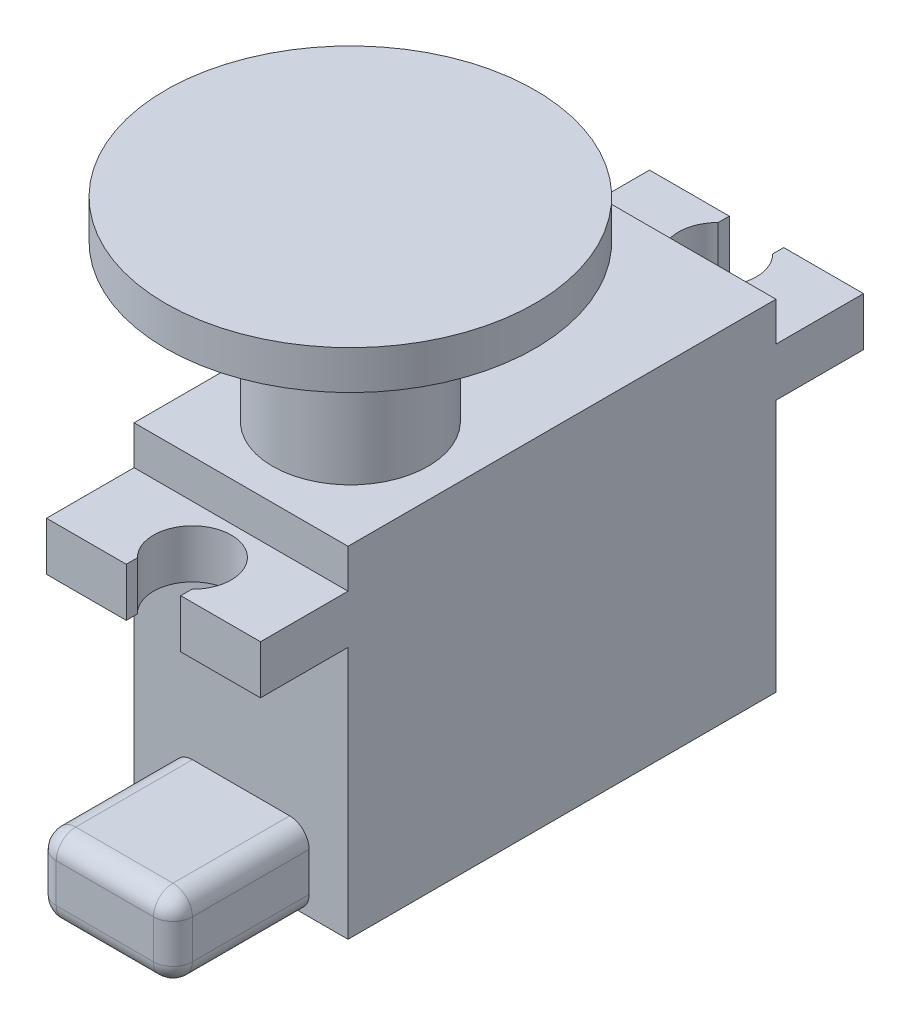
from build123d import *

# Parameters (mm, degrees)
SKETCH1_W            = 11
SKETCH1_H            = 22
BOSS_EXTRUDE1_DEPTH  = 17.5
SKETCH8_W            = 7
SKETCH8_H            = 4
BOSS_EXTRUDE6_DEPTH  = 7
FILLET1_R            = 1
FILLET2_R            = 1
SKETCH9_W            = 11
SKETCH9_H            = 2.5
BOSS_EXTRUDE7_DEPTH  = 4.5
SKETCH10_W           = 11
SKETCH10_H           = 2.5
BOSS_EXTRUDE8_DEPTH  = 4.5
CUT_EXTRUDE1_DEPTH   = 5
SKETCH2_R            = 4
BOSS_EXTRUDE9_DEPTH  = 8
SKETCH13_R           = 9.5
BOSS_EXTRUDE10_DEPTH = 2


with BuildPart() as part:
    # Sketch1 → Boss-Extrude1 (new body)
    with BuildSketch(Plane(origin=(0, 0, 0), x_dir=(1, 0, 0), z_dir=(0, 1, 0))):
        Rectangle(SKETCH1_W, SKETCH1_H)
    extrude(amount=BOSS_EXTRUDE1_DEPTH)

    # Sketch8 → Boss-Extrude6 (add)
    with BuildSketch(Plane.XY.offset(11)):
        with Locations((0, 2)):
            Rectangle(SKETCH8_W, SKETCH8_H)
    extrude(amount=BOSS_EXTRUDE6_DEPTH)

    # Fillet1
    fillet1_edges = [part.edges().sort_by_distance(p)[0] for p in [
        (-3.5, 0, 14.5),
        (-3.5, 4, 14.5),
        (3.5, 4, 14.5),
        (3.5, 0, 14.5),
    ]]
    fillet(fillet1_edges, radius=FILLET1_R)

    # Fillet2
    fillet2_edges = [part.edges().sort_by_distance(p)[0] for p in [
        (0, 0, 18),
        (-3.5, 2, 18),
        (3.5, 2, 18),
        (0, 4, 18),
        (3.207106781, 0.292893219, 18),
        (3.207106781, 3.707106781, 18),
        (-3.207106781, 3.707106781, 18),
        (-3.207106781, 0.292893219, 18),
    ]]
    fillet(fillet2_edges, radius=FILLET2_R)

    # Sketch9 → Boss-Extrude7 (add)
    with BuildSketch(Plane.XY.offset(11)):
        with Locations((0, 14.25)):
            Rectangle(SKETCH9_W, SKETCH9_H)
    extrude(amount=BOSS_EXTRUDE7_DEPTH)

    # Sketch10 → Boss-Extrude8 (add)
    with BuildSketch(Plane(origin=(0, 0, -11), x_dir=(-1, 0, 0), z_dir=(0, 0, -1))):
        with Locations((0, 14.25)):
            Rectangle(SKETCH10_W, SKETCH10_H)
    extrude(amount=BOSS_EXTRUDE8_DEPTH)

    # Sketch11 → Cut-Extrude1 (cut)
    with BuildSketch(Plane(origin=(0, 17.5, 0), x_dir=(1, 0, 0), z_dir=(0, 1, 0))):
        with BuildLine():
            Line((1.4, 15.5), (1.4, 14.928285686))
            ThreePointArc((1.4, 14.928285686), (0, 11.5), (-1.4, 14.928285686))
            Line((-1.4, 14.928285686), (-1.4, 15.5))
            Line((-1.4, 15.5), (1.4, 15.5))
        make_face()
        with BuildLine():
            Line((-1.4, -15.5), (-1.4, -14.928285686))
            ThreePointArc((-1.4, -14.928285686), (0, -11.5), (1.4, -14.928285686))
            Line((1.4, -14.928285686), (1.4, -15.5))
            Line((1.4, -15.5), (-1.4, -15.5))
        make_face()
    extrude(amount=-CUT_EXTRUDE1_DEPTH, mode=Mode.SUBTRACT)

    # Sketch2 → Boss-Extrude9 (add)
    with BuildSketch(Plane(origin=(0, 17.5, 0), x_dir=(1, 0, 0), z_dir=(0, 1, 0))):
        with Locations((0, -5.38022134)):
            Circle(SKETCH2_R)
    extrude(amount=BOSS_EXTRUDE9_DEPTH)

    # Sketch13 → Boss-Extrude10 (add)
    with BuildSketch(Plane(origin=(0, 25.5, 0), x_dir=(1, 0, 0), z_dir=(0, 1, 0))):
        with Locations((0, -5.38022134)):
            Circle(SKETCH13_R)
    extrude(amount=BOSS_EXTRUDE10_DEPTH)


solid = part.part
